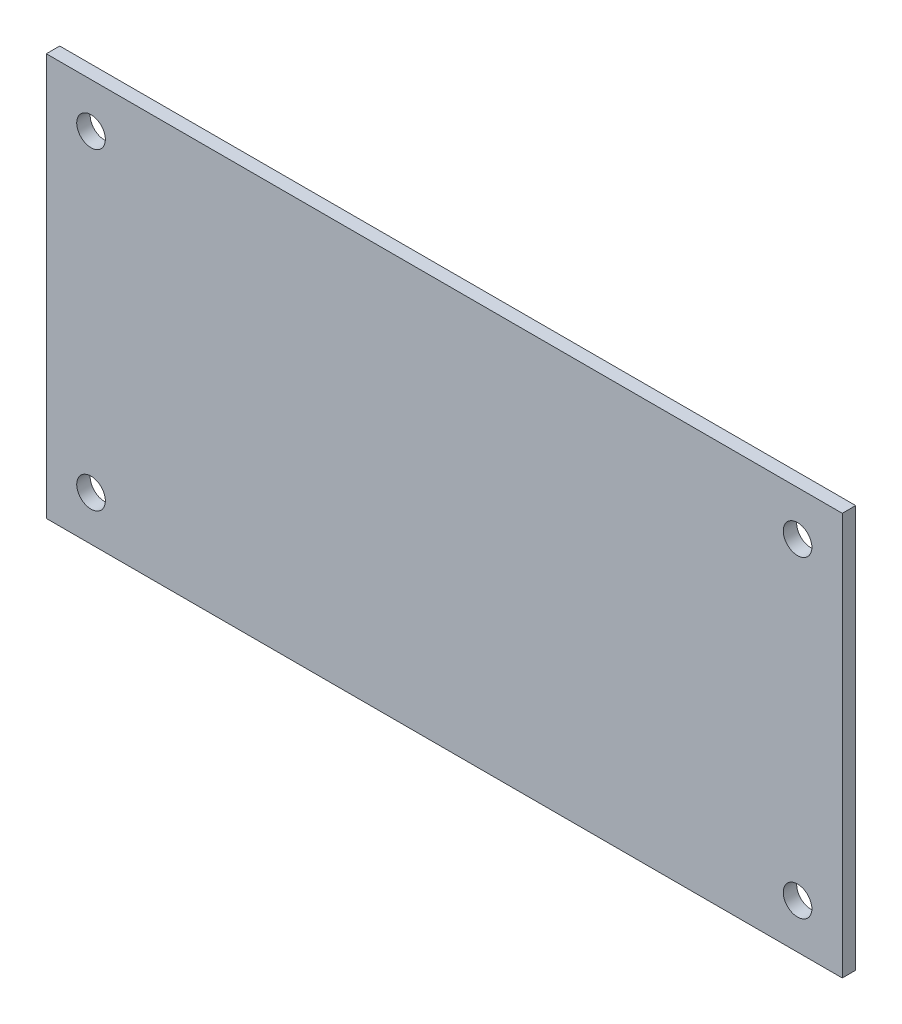
from build123d import *

# Parameters (mm, degrees)
ESQUISSE1_W = 89
ESQUISSE1_H = 45
ESQUISSE1_R = 1.6
MAIN_DEPTH  = 1.5


with BuildPart() as part:
    # Esquisse1 → Main (new body)
    with BuildSketch(Plane.XY):
        Rectangle(ESQUISSE1_W, ESQUISSE1_H)
        with Locations((-39.5, 17.5)):
            Circle(ESQUISSE1_R, mode=Mode.SUBTRACT)
        with Locations((-39.5, -17.5)):
            Circle(ESQUISSE1_R, mode=Mode.SUBTRACT)
        with Locations((39.5, -17.5)):
            Circle(ESQUISSE1_R, mode=Mode.SUBTRACT)
        with Locations((39.5, 17.5)):
            Circle(ESQUISSE1_R, mode=Mode.SUBTRACT)
    extrude(amount=MAIN_DEPTH)


solid = part.part
